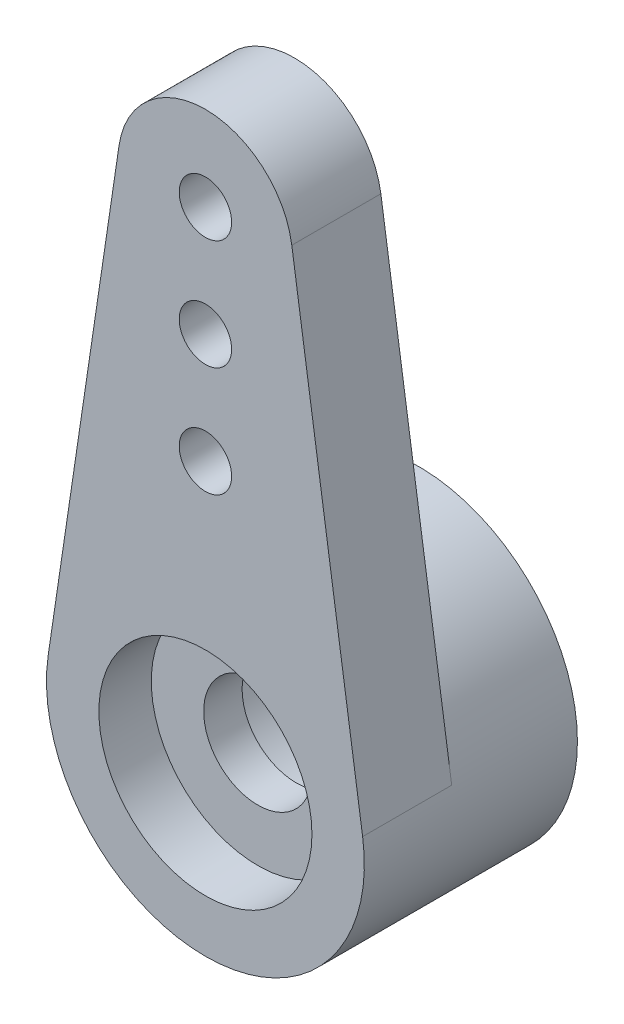
from build123d import *

# Parameters (mm, degrees)
ESQUISSE1_R                     = 0.75
BOSS_EXTRU_1_DEPTH              = 2.55
ESQUISSE2_R                     = 4.55
BOSS_EXTRU_2_DEPTH              = 3.55
ESQUISSE3_R                     = 3.05
ENL_V_MAT_EXTRU_1_DEPTH         = 1.5
DIAM_TRE_DU_PER_AGE_3_1_3_1_1_D = 3.1
ESQUISSE6_R                     = 2.75
ENL_V_MAT_EXTRU_2_DEPTH         = 3.5


with BuildPart() as part:
    # Esquisse1 → Boss.-Extru.1 (new body)
    with BuildSketch(Plane.XY):
        with BuildLine():
            Line((-4.500602541, 0.668637993), (-2.472858539, 14.317383513))
            ThreePointArc((-2.472858539, 14.317383513), (0, 16.45), (2.472858539, 14.317383513))
            Line((2.472858539, 14.317383513), (4.500602541, 0.668637993))
            ThreePointArc((4.500602541, 0.668637993), (0, -4.55), (-4.500602541, 0.668637993))
        make_face()
        with Locations((0, 7.725)):
            Circle(ESQUISSE1_R, mode=Mode.SUBTRACT)
        with Locations((0, 10.875)):
            Circle(ESQUISSE1_R, mode=Mode.SUBTRACT)
        with Locations((0, 14.025)):
            Circle(ESQUISSE1_R, mode=Mode.SUBTRACT)
    extrude(amount=BOSS_EXTRU_1_DEPTH)

    # Esquisse2 → Boss.-Extru.2 (add)
    with BuildSketch(Plane(origin=(0, 0, 0), x_dir=(-1, 0, 0), z_dir=(0, 0, -1))):
        Circle(ESQUISSE2_R)
    extrude(amount=BOSS_EXTRU_2_DEPTH)

    # Esquisse3 → Enlèv. mat.-Extru.1 (cut)
    with BuildSketch(Plane.XY.offset(2.55)):
        Circle(ESQUISSE3_R)
    extrude(amount=-ENL_V_MAT_EXTRU_1_DEPTH, mode=Mode.SUBTRACT)

    # Diamètre du perçage Ø3.1 (3.1)1 (through all)
    with Locations(Plane.XY.offset(1.05)):
        with Locations((0, 0)):
            Hole(DIAM_TRE_DU_PER_AGE_3_1_3_1_1_D / 2)

    # Esquisse6 → Enlèv. mat.-Extru.2 (cut)
    with BuildSketch(Plane(origin=(0, 0, -3.55), x_dir=(-1, 0, 0), z_dir=(0, 0, -1))):
        Circle(ESQUISSE6_R)
    extrude(amount=-ENL_V_MAT_EXTRU_2_DEPTH, mode=Mode.SUBTRACT)


solid = part.part
